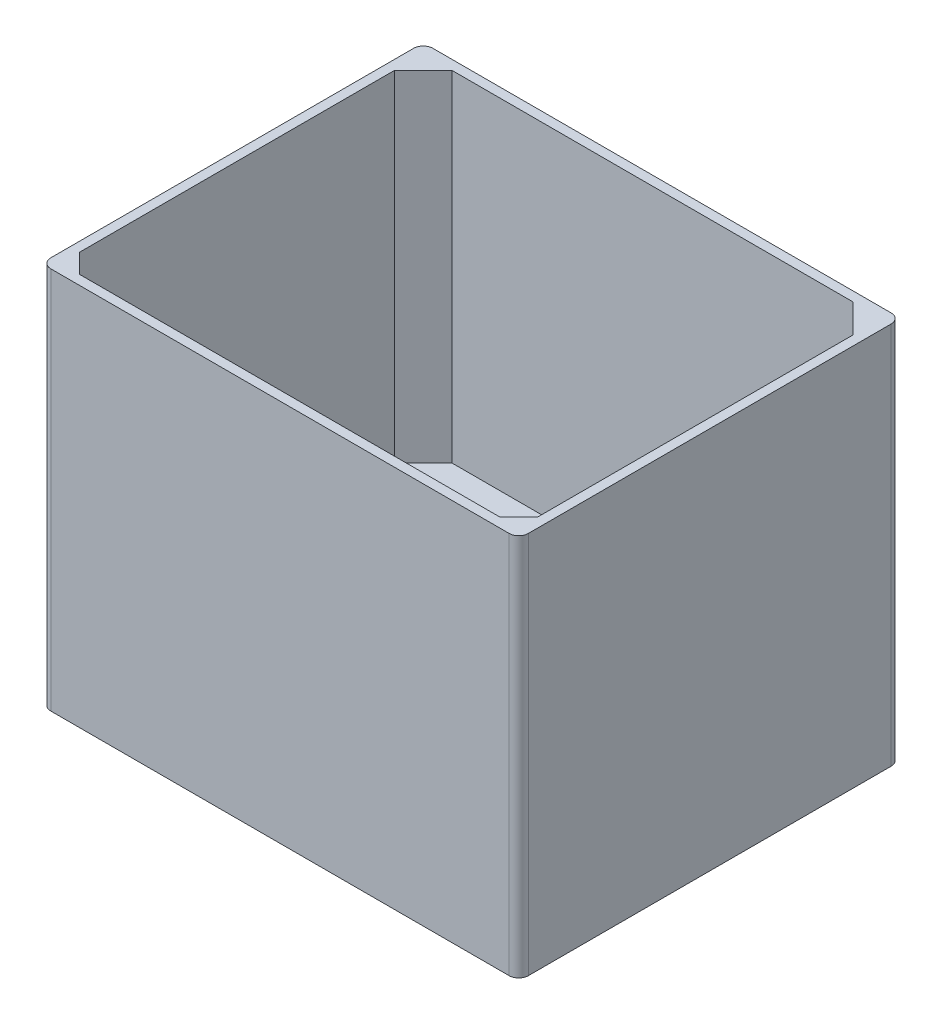
from build123d import *

# Parameters (mm, degrees)
SKETCH1_W                 = 100
SKETCH1_H                 = 80
BOSS_EXTRUDE1_DEPTH       = 80.217571917
SHELL1_T                  = -2
SHELL1_THICKNESS_2_FACE_W = 76
SHELL1_THICKNESS_2_FACE_H = 96
SHELL1_THICKNESS_2_DEPTH  = 7
CUT_EXTRUDE2_DEPTH        = 180
FILLET3_R                 = 2
FILLET4_R                 = 2
CHAMFER2_SIZE             = 6
CHAMFER3_SIZE             = 6
CHAMFER4_SIZE             = 4
SKETCH4_W                 = 85
SKETCH4_H                 = 44
CUT_EXTRUDE3_DEPTH        = 1


with BuildPart() as part:
    # Sketch1 → Boss-Extrude1 (new body)
    with BuildSketch(Plane(origin=(0, 0, 0), x_dir=(1, 0, 0), z_dir=(0, 1, 0))):
        with Locations((9.074074074, -6.574074074)):
            Rectangle(SKETCH1_W, SKETCH1_H)
    extrude(amount=BOSS_EXTRUDE1_DEPTH)

    # Shell1
    shell1_openings = [part.faces().sort_by_distance(p)[0] for p in [
        (9.074074074, 80.217571917, 6.574074074),
    ]]
    offset(amount=SHELL1_T, openings=shell1_openings, kind=Kind.INTERSECTION)

    # Shell1 thickness 2 face (on inner face of the shell) → Shell1 thickness 2 (add)
    with BuildSketch(Plane(origin=(9.074074074, 2, 6.574074074), x_dir=(0, 0, -1), z_dir=(0, -1, 0))):
        Rectangle(SHELL1_THICKNESS_2_FACE_W, SHELL1_THICKNESS_2_FACE_H)
    extrude(amount=-SHELL1_THICKNESS_2_DEPTH)

    # Sketch3 → Cut-Extrude2 (cut)
    with BuildSketch(Plane(origin=(0, 80.217571917, 0), x_dir=(1, 0, 0), z_dir=(0, 1, 0))):
        Polygon((9.074074074, -1.163150467), (46.843833128, -1.163150467), (46.843833128, -42.758682986), (9.074074074, -42.758682986), (-28.653994459, -42.758682986), (-28.653994459, -1.163150467), align=None)
    extrude(amount=-CUT_EXTRUDE2_DEPTH, mode=Mode.SUBTRACT)

    # Fillet3
    fillet3_edges = [part.edges().sort_by_distance(p)[0] for p in [
        (-40.925925926, 40.108785958, 46.574074074),
    ]]
    fillet(fillet3_edges, radius=FILLET3_R)

    # Fillet4
    fillet4_edges = [part.edges().sort_by_distance(p)[0] for p in [
        (-40.925925926, 40.108785958, -33.425925926),
        (59.074074074, 40.108785958, -33.425925926),
        (59.074074074, 40.108785958, 46.574074074),
    ]]
    fillet(fillet4_edges, radius=FILLET4_R)

    # Chamfer2
    chamfer2_edges = [part.edges().sort_by_distance(p)[0] for p in [
        (-38.925925926, 44.608785958, -31.425925926),
    ]]
    chamfer(chamfer2_edges, length=CHAMFER2_SIZE)

    # Chamfer3
    chamfer3_edges = [part.edges().sort_by_distance(p)[0] for p in [
        (57.074074074, 44.608785958, -31.425925926),
    ]]
    chamfer(chamfer3_edges, length=CHAMFER3_SIZE)

    # Chamfer4
    chamfer4_edges = [part.edges().sort_by_distance(p)[0] for p in [
        (-38.925925926, 44.608785958, 44.574074074),
        (57.074074074, 44.608785958, 44.574074074),
    ]]
    chamfer(chamfer4_edges, length=CHAMFER4_SIZE)

    # Sketch4 → Cut-Extrude3 (cut)
    with BuildSketch(Plane.XZ):
        with Locations((9.08325413, 20.764850692)):
            Rectangle(SKETCH4_W, SKETCH4_H)
    extrude(amount=-CUT_EXTRUDE3_DEPTH, mode=Mode.SUBTRACT)


solid = part.part
